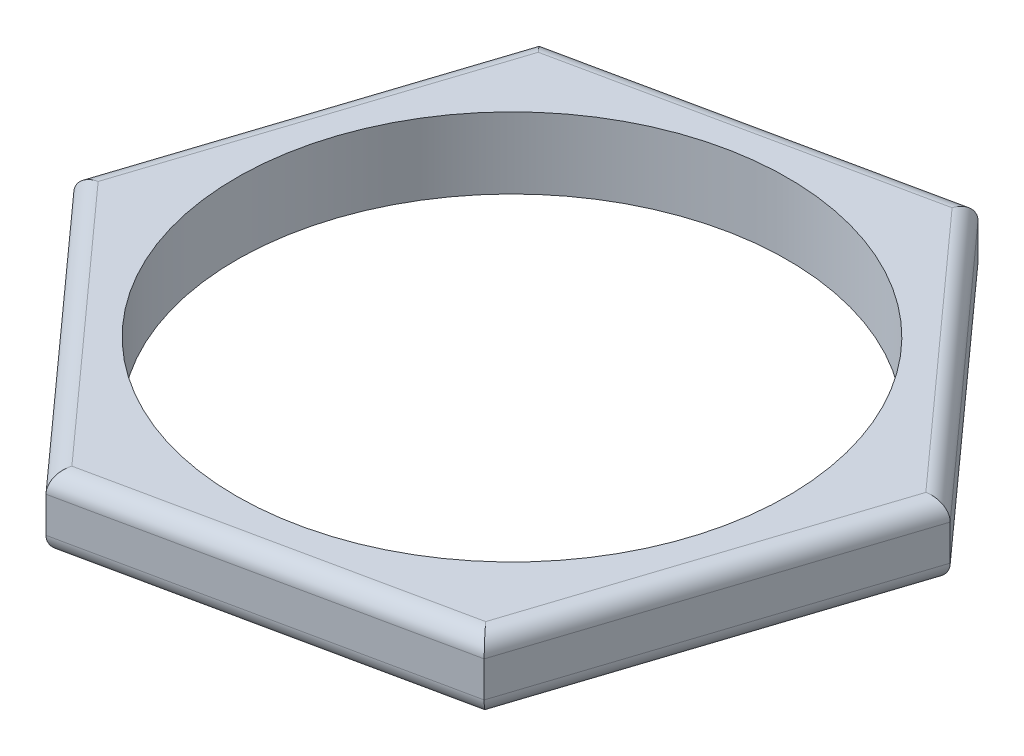
from build123d import *

# Parameters (mm, degrees)
SKETCH_1_R      = 15.5
EXTRUDE_1_DEPTH = 4
FILLET_1_R      = 1


with BuildPart() as part:
    # 草图1 → 凸台-拉伸1 (new body)
    with BuildSketch(Plane(origin=(0, 0, 0), x_dir=(1, 0, 0), z_dir=(0, 1, 0))):
        Polygon((13.894572462, -15.457711864), (20.33405739, 4.304196795), (6.439484928, 19.761908659), (-13.894572462, 15.457711864), (-20.33405739, -4.304196795), (-6.439484928, -19.761908659), align=None)
        Circle(SKETCH_1_R, mode=Mode.SUBTRACT)
    extrude(amount=EXTRUDE_1_DEPTH)

    # 圆角1
    fillet_1_edges = [part.edges().sort_by_distance(p)[0] for p in [
        (13.386771159, 4, -12.033052727),
        (-3.727543767, 4, -17.609810262),
        (-17.114314926, 4, -5.576757535),
        (-13.386771159, 4, 12.033052727),
        (3.727543767, 4, 17.609810262),
        (-13.386771159, 0, 12.033052727),
        (-17.114314926, 0, -5.576757535),
        (-3.727543767, 0, -17.609810262),
        (17.114314926, 4, 5.576757535),
        (13.386771159, 0, -12.033052727),
        (17.114314926, 0, 5.576757535),
        (3.727543767, 0, 17.609810262),
    ]]
    fillet(fillet_1_edges, radius=FILLET_1_R)


solid = part.part
